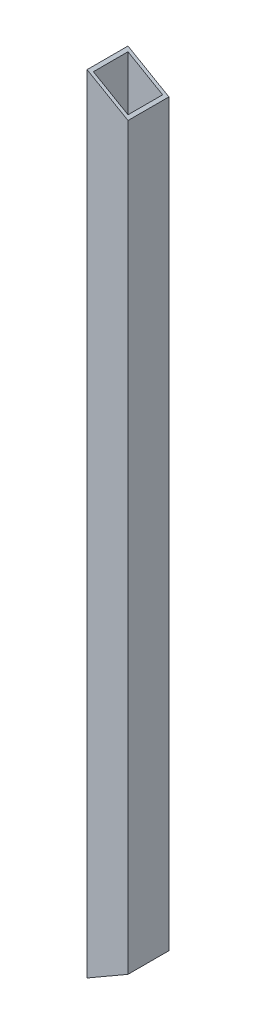
from build123d import *

# Parameters (mm, degrees)
SKETCH4_W           = 13
SKETCH4_H           = 13
SKETCH4_W_2         = 11
SKETCH4_H_2         = 11
BOSS_EXTRUDE1_DEPTH = 250
CUT_EXTRUDE1_DEPTH  = 14


with BuildPart() as part:
    # Sketch4 → Boss-Extrude1 (new body)
    with BuildSketch(Plane(origin=(0, 0, 0), x_dir=(1, 0, 0), z_dir=(0, 1, 0))):
        with Locations((0.382825357, -0.030567938)):
            Rectangle(SKETCH4_W, SKETCH4_H)
        with Locations((0.382825357, -0.030567938)):
            Rectangle(SKETCH4_W_2, SKETCH4_H_2, mode=Mode.SUBTRACT)
    extrude(amount=BOSS_EXTRUDE1_DEPTH)

    # Sketch5 → Cut-Extrude1 (cut, through all)
    with BuildSketch(Plane.XY.offset(6.530567938)):
        Polygon((6.882825357, 0), (6.882825357, 7.505553499), (-6.117174643, 0), align=None)
        Polygon((6.882825357, 250), (-6.117174643, 250), (6.882825357, 242.494446501), align=None)
    extrude(amount=-CUT_EXTRUDE1_DEPTH, mode=Mode.SUBTRACT)


solid = part.part
